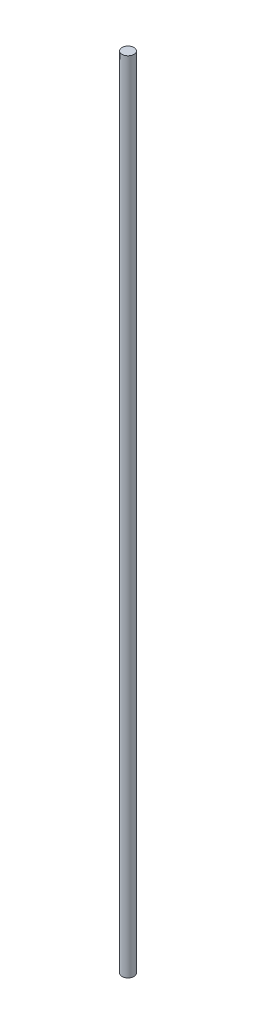
from build123d import *

# Parameters (mm, degrees)
SKETCH1_R           = 1.5
BOSS_EXTRUDE1_DEPTH = 200


with BuildPart() as part:
    # Sketch1 → Boss-Extrude1 (new body)
    with BuildSketch(Plane(origin=(0, 0, 0), x_dir=(1, 0, 0), z_dir=(0, 1, 0))):
        Circle(SKETCH1_R)
    extrude(amount=BOSS_EXTRUDE1_DEPTH)


solid = part.part
